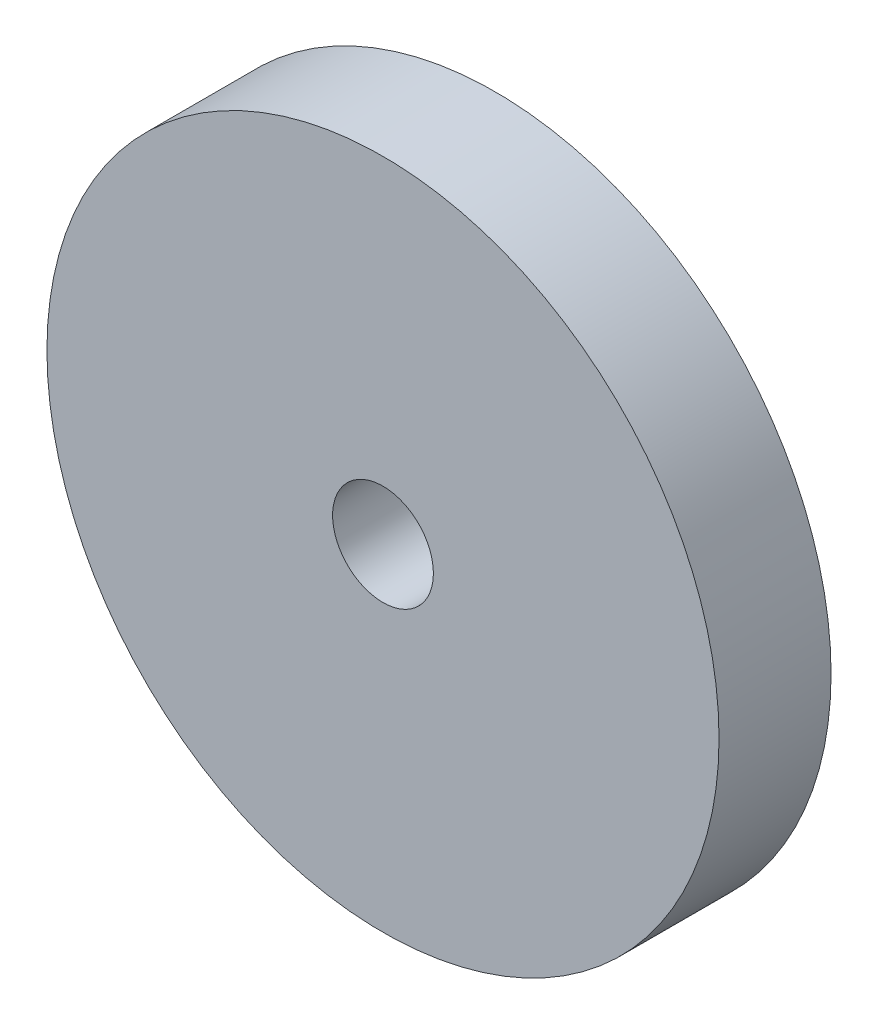
from build123d import *

# Parameters (mm, degrees)
SKETCH1_R           = 60
SKETCH1_R_2         = 9
BOSS_EXTRUDE1_DEPTH = 20


with BuildPart() as part:
    # Sketch1 → Boss-Extrude1 (new body)
    with BuildSketch(Plane.XY):
        Circle(SKETCH1_R)
        Circle(SKETCH1_R_2, mode=Mode.SUBTRACT)
    extrude(amount=BOSS_EXTRUDE1_DEPTH)


solid = part.part
